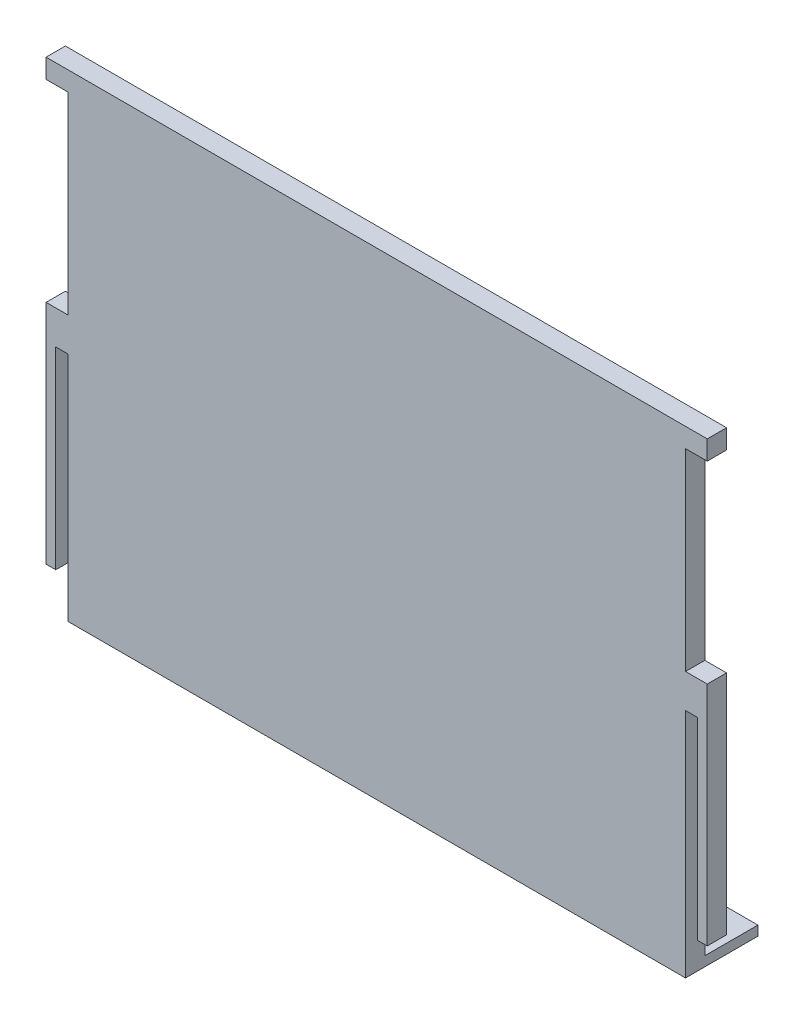
from build123d import *

# Parameters (mm, degrees)
SKETCH1_W           = 137
SKETCH1_H           = 96
BOSS_EXTRUDE1_DEPTH = 4
SKETCH2_W           = 2.5
SKETCH2_H           = 40
SKETCH2_W_2         = 4.5
CUT_EXTRUDE1_DEPTH  = 4
SKETCH3_W           = 137
SKETCH3_H           = 4
BOSS_EXTRUDE2_DEPTH = 3
SKETCH4_W           = 137
SKETCH4_H           = 2
BOSS_EXTRUDE3_DEPTH = 11
SKETCH5_W           = 4.5
SKETCH5_H           = 8
CUT_EXTRUDE2_DEPTH  = 16
SKETCH6_W           = 39.2
SKETCH6_H           = 28.2
SKETCH6_W_2         = 69.2
SKETCH6_H_2         = 54.2
CUT_EXTRUDE3_DEPTH  = 2


with BuildPart() as part:
    # Sketch1 → Boss-Extrude1 (new body)
    with BuildSketch(Plane.XY):
        Rectangle(SKETCH1_W, SKETCH1_H)
    extrude(amount=BOSS_EXTRUDE1_DEPTH)

    # Sketch2 → Cut-Extrude1 (cut)
    with BuildSketch(Plane.XY.offset(4)):
        with Locations((-65.25, -20)):
            Rectangle(SKETCH2_W, SKETCH2_H)
        with Locations((65.25, -20)):
            Rectangle(SKETCH2_W, SKETCH2_H)
        with Locations((-66.25, 27)):
            Rectangle(SKETCH2_W_2, SKETCH2_H)
        with Locations((66.25, 27)):
            Rectangle(SKETCH2_W_2, SKETCH2_H)
    extrude(amount=-CUT_EXTRUDE1_DEPTH, mode=Mode.SUBTRACT)

    # Sketch3 → Boss-Extrude2 (add)
    with BuildSketch(Plane(origin=(0, 48, 0), x_dir=(1, 0, 0), z_dir=(0, 1, 0))):
        with Locations((0, -2)):
            Rectangle(SKETCH3_W, SKETCH3_H)
    extrude(amount=BOSS_EXTRUDE2_DEPTH)

    # Sketch4 → Boss-Extrude3 (add)
    with BuildSketch(Plane(origin=(0, 0, 0), x_dir=(-1, 0, 0), z_dir=(0, 0, -1))):
        with Locations((0, -47)):
            Rectangle(SKETCH4_W, SKETCH4_H)
    extrude(amount=BOSS_EXTRUDE3_DEPTH)

    # Sketch5 → Cut-Extrude2 (cut, through all)
    with BuildSketch(Plane.XY.offset(4)):
        with Locations((-66.25, -44)):
            Rectangle(SKETCH5_W, SKETCH5_H)
        with Locations((66.25, -44)):
            Rectangle(SKETCH5_W, SKETCH5_H)
    extrude(amount=-CUT_EXTRUDE2_DEPTH, mode=Mode.SUBTRACT)

    # Sketch6 → Cut-Extrude3 (cut)
    with BuildSketch(Plane(origin=(0, 0, 0), x_dir=(-1, 0, 0), z_dir=(0, 0, -1))):
        with Locations((-40.4, -30.2)):
            Rectangle(SKETCH6_W, SKETCH6_H)
        with Locations((40.4, -30.2)):
            Rectangle(SKETCH6_W, SKETCH6_H)
        with Locations((0, 17.8)):
            Rectangle(SKETCH6_W_2, SKETCH6_H_2)
    extrude(amount=-CUT_EXTRUDE3_DEPTH, mode=Mode.SUBTRACT)


solid = part.part
